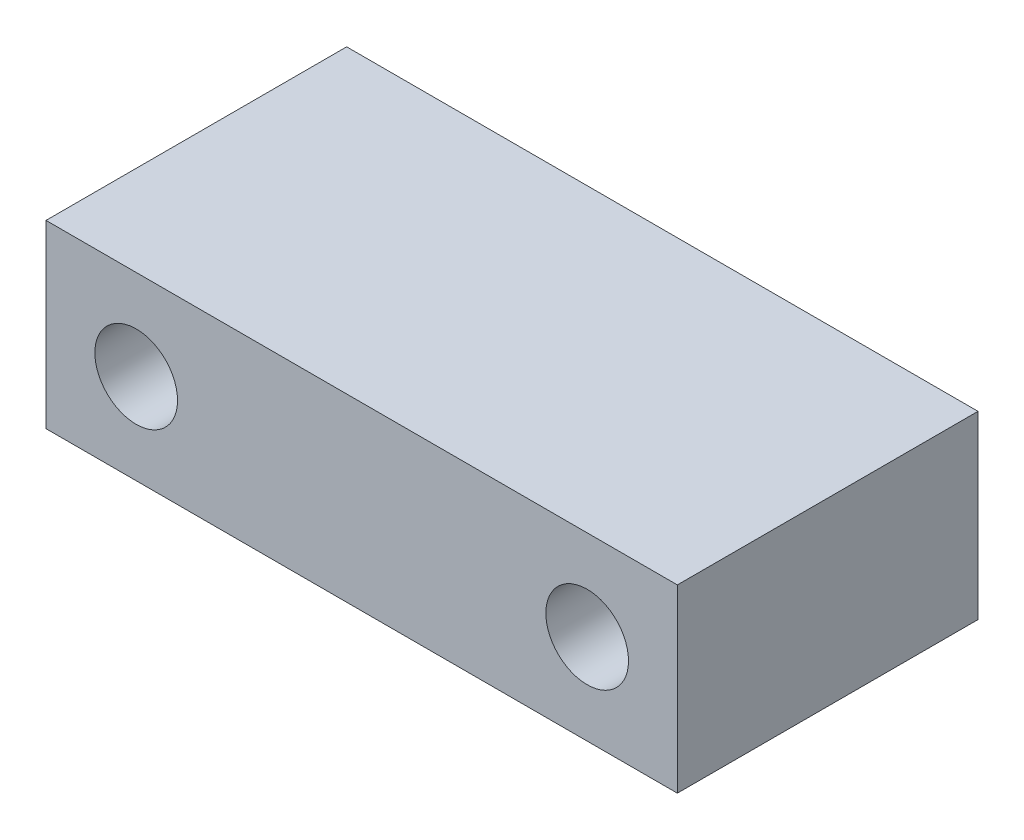
from build123d import *

# Parameters (mm, degrees)
SKETCH_1_W                  = 42
SKETCH_1_H                  = 12
EXTRUDE_1_DEPTH             = 20
HOLE_WIZARD_5_5_5_5_1_D     = 5.5
HOLE_WIZARD_5_5_5_5_1_DEPTH = 20


with BuildPart() as part:
    # 草图1 → 凸台-拉伸1 (new body)
    with BuildSketch(Plane.XY):
        Rectangle(SKETCH_1_W, SKETCH_1_H)
    extrude(amount=EXTRUDE_1_DEPTH)

    # Ø5.5 (5.5) 直径孔1
    with Locations(Plane.XY.offset(20)):
        with Locations((-15, 0), (15, 0)):
            Hole(HOLE_WIZARD_5_5_5_5_1_D / 2, depth=HOLE_WIZARD_5_5_5_5_1_DEPTH)


solid = part.part
